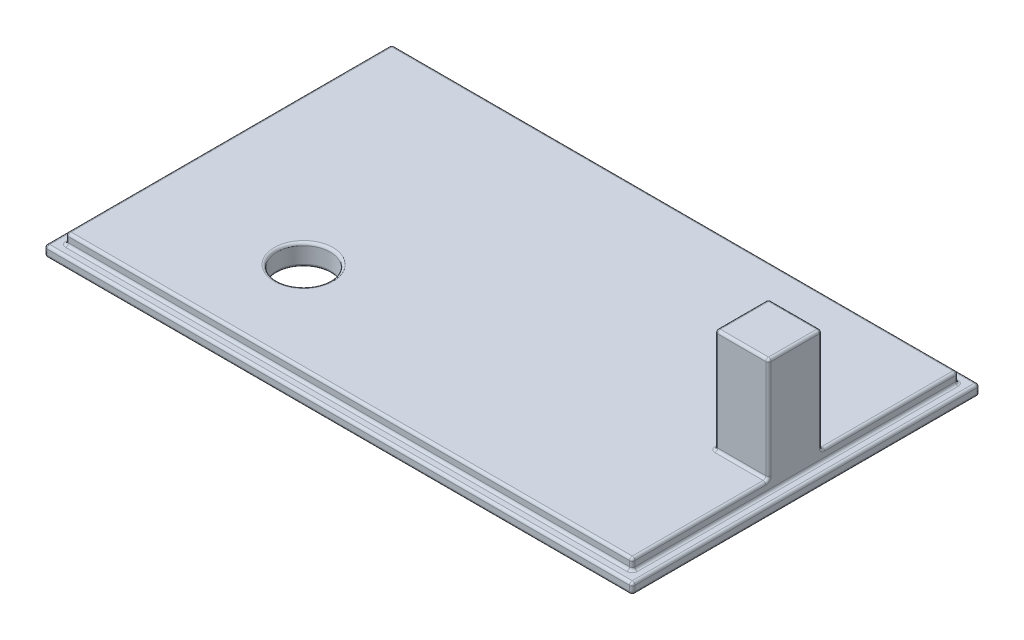
from build123d import *

# Parameters (mm, degrees)
SKETCH1_W           = 110
SKETCH1_H           = 65
BOSS_EXTRUDE1_DEPTH = 2
SKETCH2_W           = 106
SKETCH2_H           = 61
BOSS_EXTRUDE3_DEPTH = 2
SKETCH6_W           = 10
SKETCH6_H           = 10
BOSS_EXTRUDE4_DEPTH = 19.5
SKETCH7_R           = 5
CUT_EXTRUDE1_DEPTH  = 5
FILLET1_R           = 0.5


with BuildPart() as part:
    # Sketch1 → Boss-Extrude1 (new body)
    with BuildSketch(Plane(origin=(0, 0, 0), x_dir=(1, 0, 0), z_dir=(0, 1, 0))):
        with Locations((-2.954873439, 1.833455829)):
            Rectangle(SKETCH1_W, SKETCH1_H)
    extrude(amount=BOSS_EXTRUDE1_DEPTH)

    # Sketch2 → Boss-Extrude3 (add)
    with BuildSketch(Plane(origin=(0, 2, 0), x_dir=(1, 0, 0), z_dir=(0, 1, 0))):
        with Locations((-2.954873439, 1.833455829)):
            Rectangle(SKETCH2_W, SKETCH2_H)
    extrude(amount=BOSS_EXTRUDE3_DEPTH)

    # Sketch6 → Boss-Extrude4 (add)
    with BuildSketch(Plane(origin=(0, 4, 0), x_dir=(1, 0, 0), z_dir=(0, 1, 0))):
        with Locations((45.045126561, 1.833455829)):
            Rectangle(SKETCH6_W, SKETCH6_H)
    extrude(amount=BOSS_EXTRUDE4_DEPTH)

    # Sketch7 → Cut-Extrude1 (cut, through all)
    with BuildSketch(Plane(origin=(0, 4, 0), x_dir=(1, 0, 0), z_dir=(0, 1, 0))):
        with Locations((-28.454873439, -11.666544171)):
            Circle(SKETCH7_R)
    extrude(amount=-CUT_EXTRUDE1_DEPTH, mode=Mode.SUBTRACT)

    # Fillet1
    fillet1_edges = [part.edges().sort_by_distance(p)[0] for p in [
        (52.045126561, 2, -1.833455829),
        (-2.954873439, 2, -34.333455829),
        (-2.954873439, 4, -32.333455829),
        (50.045126561, 3, -32.333455829),
        (-55.954873439, 2, -1.833455829),
        (-55.954873439, 3, -32.333455829),
        (-2.954873439, 2, 28.666544171),
        (-55.954873439, 3, 28.666544171),
        (50.045126561, 4, -19.583455829),
        (50.045126561, 3, 28.666544171),
        (-55.954873439, 4, -1.833455829),
        (-2.954873439, 4, 28.666544171),
        (-2.954873439, 2, -32.333455829),
        (50.045126561, 2, -1.833455829),
        (50.045126561, 4, 15.916544171),
        (50.045126561, 23.5, -1.833455829),
        (50.045126561, 13.75, 3.166544171),
        (45.045126561, 4, -6.833455829),
        (50.045126561, 13.75, -6.833455829),
        (40.045126561, 4, -1.833455829),
        (40.045126561, 13.75, -6.833455829),
        (45.045126561, 23.5, 3.166544171),
        (40.045126561, 13.75, 3.166544171),
        (45.045126561, 23.5, -6.833455829),
        (40.045126561, 23.5, -1.833455829),
        (45.045126561, 4, 3.166544171),
        (-57.954873439, 2, -1.833455829),
        (-33.454873439, 0, 11.666544171),
        (-33.454873439, 4, 11.666544171),
        (-2.954873439, 0, -34.333455829),
        (52.045126561, 0, -1.833455829),
        (-2.954873439, 0, 30.666544171),
        (-57.954873439, 0, -1.833455829),
        (-2.954873439, 2, 30.666544171),
        (-57.954873439, 1, -34.333455829),
        (52.045126561, 1, -34.333455829),
        (52.045126561, 1, 30.666544171),
        (-57.954873439, 1, 30.666544171),
    ]]
    fillet(fillet1_edges, radius=FILLET1_R)


solid = part.part
